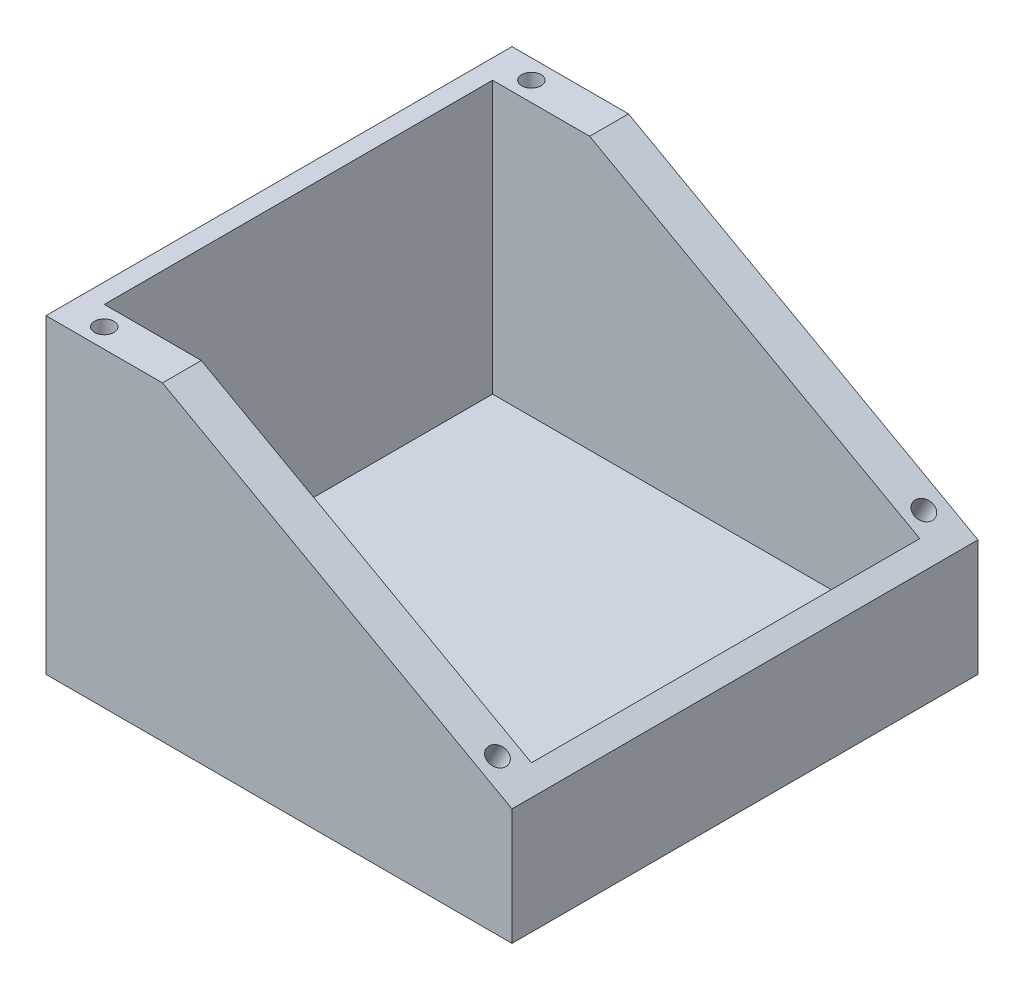
from build123d import *

# Parameters (mm, degrees)
SKETCH1_W           = 152.4
SKETCH1_H           = 101.6
BOSS_EXTRUDE1_DEPTH = 152.4
CUT_EXTRUDE2_DEPTH  = 152.4
SKETCH7_W           = 139.7
SKETCH7_H           = 127
CUT_EXTRUDE3_DEPTH  = 88.9
SKETCH8_R           = 3.175
CUT_EXTRUDE4_DEPTH  = 12.7
SKETCH9_R           = 3.175
CUT_EXTRUDE5_DEPTH  = 12.7


with BuildPart() as part:
    # Sketch1 → Boss-Extrude1 (new body)
    with BuildSketch(Plane.XY):
        with Locations((76.2, 50.8)):
            Rectangle(SKETCH1_W, SKETCH1_H)
    extrude(amount=BOSS_EXTRUDE1_DEPTH)

    # Sketch6 → Cut-Extrude2 (cut)
    with BuildSketch(Plane.XY.offset(152.4)):
        Polygon((104.436678767, 101.6), (38.1, 101.6), (152.4, 38.1), (152.4, 101.6), (104.590197544, 101.6), align=None)
    extrude(amount=-CUT_EXTRUDE2_DEPTH, mode=Mode.SUBTRACT)

    # Sketch7 → Cut-Extrude3 (cut)
    with BuildSketch(Plane(origin=(0, 101.6, 0), x_dir=(1, 0, 0), z_dir=(0, 1, 0))):
        with Locations((76.2, -76.2)):
            Rectangle(SKETCH7_W, SKETCH7_H)
    extrude(amount=-CUT_EXTRUDE3_DEPTH, mode=Mode.SUBTRACT)

    # Sketch8 → Cut-Extrude4 (cut)
    with BuildSketch(Plane(origin=(0, 101.6, 0), x_dir=(1, 0, 0), z_dir=(0, 1, 0))):
        with Locations((12.7, -146.05)):
            Circle(SKETCH8_R)
        with Locations((12.7, -6.35)):
            Circle(SKETCH8_R)
    extrude(amount=-CUT_EXTRUDE4_DEPTH, mode=Mode.SUBTRACT)

    # Sketch9 → Cut-Extrude5 (cut)
    with BuildSketch(Plane(origin=(52.117924528, 93.812264151, 0), x_dir=(0.874157276, -0.485642931, 0), z_dir=(0.485642931, 0.874157276, 0))):
        with Locations((102.018573203, -146.05)):
            Circle(SKETCH9_R)
        with Locations((102.018573203, -6.604)):
            Circle(SKETCH9_R)
    extrude(amount=-CUT_EXTRUDE5_DEPTH, mode=Mode.SUBTRACT)


solid = part.part
